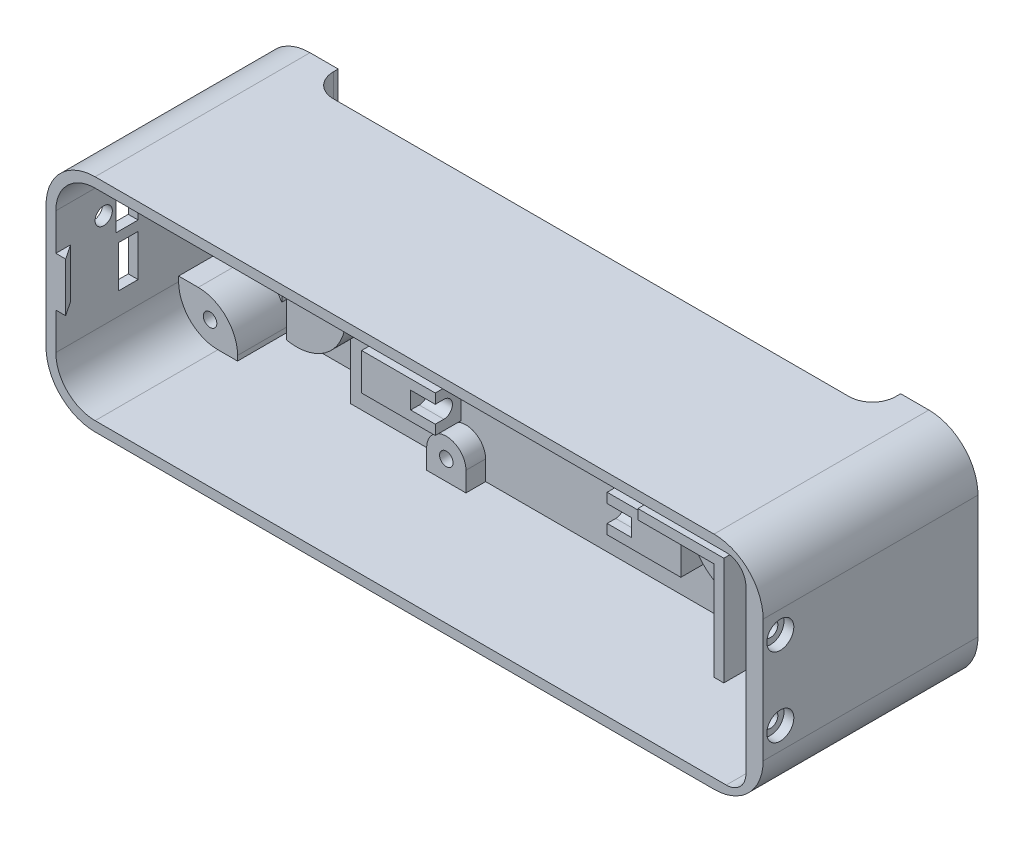
from build123d import *

# Parameters (mm, degrees)
BOSS_EXTRUDE1_DEPTH            = 7.75
CUT_EXTRUDE1_DEPTH             = 153.974058258
CUT_EXTRUDE1_DEPTH_BACK        = 153.974058258
SKETCH4_W                      = 80
SKETCH4_H                      = 45
BOSS_EXTRUDE2_DEPTH            = 6
SKETCH5_W                      = 70
SKETCH5_H                      = 35
CUT_EXTRUDE2_DEPTH             = 7
SKETCH7_R                      = 10
BOSS_EXTRUDE3_DEPTH            = 12
SKETCH6_R                      = 8.125
CUT_EXTRUDE4_DEPTH             = 7
CUT_EXTRUDE4_DEPTH_BACK        = 7
BOSS_EXTRUDE9_DEPTH            = 35
CUT_EXTRUDE5_REACH             = 155.229
SKETCH8_W                      = 25
SKETCH8_H                      = 11
CUT_EXTRUDE5_DIRECTION_2_DEPTH = 154.228791392
BOSS_EXTRUDE4_DEPTH            = 35
BOSS_EXTRUDE6_DEPTH            = 27.5
SKETCH15_W                     = 12
SKETCH15_H                     = 5
CUT_EXTRUDE8_DEPTH             = 157.735445924
CUT_EXTRUDE8_DEPTH_BACK        = 4.5
SKETCH18_W                     = 15
SKETCH18_H                     = 7.5
SKETCH18_W_2                   = 13.5
SKETCH18_W_3                   = 12.5
BOSS_EXTRUDE8_DEPTH            = 5.25
CUT_EXTRUDE16_DEPTH            = 40
CUT_EXTRUDE16_DEPTH_BACK       = 5
CUT_EXTRUDE14_DEPTH            = 5
CUT_EXTRUDE15_DEPTH            = 5
BOSS_EXTRUDE10_DEPTH           = 10
BOSS_EXTRUDE21_DEPTH           = 4
SKETCH24_R                     = 1.375
CUT_EXTRUDE13_DEPTH            = 6
CUT_EXTRUDE17_REACH            = 156.685
SKETCH30_R                     = 2.5
BOSS_EXTRUDE22_DEPTH           = 6
CUT_EXTRUDE18_DEPTH            = 3
SKETCH33_R                     = 1.75
CUT_EXTRUDE19_DEPTH            = 3
CUT_EXTRUDE20_REACH            = 144.705
SKETCH35_W                     = 3
SKETCH35_H                     = 8.75
SKETCH36_R                     = 2.75
CUT_EXTRUDE21_DEPTH            = 2
SKETCH37_R                     = 1.5
CUT_EXTRUDE22_DEPTH            = 1.5
BOSS_EXTRUDE23_DEPTH           = 5
BOSS_EXTRUDE23_DEPTH_BACK      = 5
CUT_EXTRUDE23_REACH            = 160.646
SKETCH39_W                     = 4.5
SKETCH39_H                     = 8.5
SKETCH39_W_2                   = 4
SKETCH39_R                     = 1.75
CUT_EXTRUDE24_DEPTH            = 12
CUT_EXTRUDE26_DEPTH            = 1
CHAMFER1_SIZE                  = 7
BOSS_EXTRUDE24_DEPTH           = 1


with BuildPart() as part:
    # Sketch2 → Boss-Extrude1 (new body)
    with BuildSketch(Plane.XY):
        with BuildLine():
            Line((-10, 0), (-136, 0))
            ThreePointArc((-136, 0), (-143.071067812, 2.928932188), (-146, 10))
            Line((-146, 10), (-146, 35))
            ThreePointArc((-146, 35), (-143.071067812, 42.071067812), (-136, 45))
            Line((-136, 45), (-10, 45))
            ThreePointArc((-10, 45), (-2.928932188, 42.071067812), (0, 35))
            Line((0, 35), (0, 10))
            ThreePointArc((0, 10), (-2.928932188, 2.928932188), (-10, 0))
        make_face()
    extrude(amount=BOSS_EXTRUDE1_DEPTH)

    # Sketch3 → Cut-Extrude1 (cut, two sides)
    with BuildSketch(Plane.XZ) as cut_extrude1_sk:
        with BuildLine():
            Line((-15.75, 0), (-130.25, 0))
            ThreePointArc((-130.25, 0), (-128.858757211, 3.358757211), (-125.5, 4.75))
            Line((-125.5, 4.75), (-20.5, 4.75))
            ThreePointArc((-20.5, 4.75), (-17.141242789, 3.358757211), (-15.75, 0))
        make_face()
    extrude(amount=CUT_EXTRUDE1_DEPTH, mode=Mode.SUBTRACT)
    extrude(cut_extrude1_sk.sketch, amount=-CUT_EXTRUDE1_DEPTH_BACK, mode=Mode.SUBTRACT)

    # Sketch4 → Boss-Extrude2 (add)
    with BuildSketch(Plane.XY.offset(7.75)):
        with Locations((-73, 22.5)):
            Rectangle(SKETCH4_W, SKETCH4_H)
    extrude(amount=BOSS_EXTRUDE2_DEPTH)

    # Sketch5 → Cut-Extrude2 (cut)
    with BuildSketch(Plane(origin=(0, 0, 4.75), x_dir=(-1, 0, 0), z_dir=(0, 0, -1))):
        with Locations((73, 22.5)):
            Rectangle(SKETCH5_W, SKETCH5_H)
    extrude(amount=-CUT_EXTRUDE2_DEPTH, mode=Mode.SUBTRACT)

    # Sketch7 → Boss-Extrude3 (add)
    with BuildSketch(Plane.XY.offset(7.75)):
        with Locations(Location((-28, 22.5, 0), (0, 0, 180))):
            Circle(SKETCH7_R)
        with Locations(Location((-118, 22.5, 0), (0, 0, 180))):
            Circle(SKETCH7_R)
    extrude(amount=BOSS_EXTRUDE3_DEPTH)

    # Sketch6 → Cut-Extrude4 (cut, two sides)
    with BuildSketch(Plane(origin=(0, 0, 4.75), x_dir=(-1, 0, 0), z_dir=(0, 0, -1))) as cut_extrude4_sk:
        with Locations(Location((118, 22.5, 0), (0, 0, 22.619864948))):
            Circle(SKETCH6_R)
        with Locations(Location((28, 22.5, 0), (0, 0, 157.380135052))):
            Circle(SKETCH6_R)
    extrude(amount=CUT_EXTRUDE4_DEPTH, mode=Mode.SUBTRACT)
    extrude(cut_extrude4_sk.sketch, amount=-CUT_EXTRUDE4_DEPTH_BACK, mode=Mode.SUBTRACT)

    # Sketch22 → Boss-Extrude9 (add)
    with BuildSketch(Plane.XZ.offset(-40)):
        Polygon((-73, 8.25), (-73, 11.75), (-92.849486369, 11.75), align=None)
        Polygon((-53.150513631, 11.75), (-73, 11.75), (-73, 8.25), align=None)
    extrude(amount=BOSS_EXTRUDE9_DEPTH)

    # Sketch8 → Cut-Extrude5 (cut, up to next)
    with BuildSketch(Plane(origin=(0, 0, 11.75), x_dir=(-1, 0, 0), z_dir=(0, 0, -1)), mode=Mode.PRIVATE) as cut_extrude5_sk1:
        with Locations((73, 22.5)):
            Rectangle(SKETCH8_W, SKETCH8_H)
    cut_extrude5_tool1 = extrude(cut_extrude5_sk1.sketch, amount=-CUT_EXTRUDE5_REACH, mode=Mode.PRIVATE) & part.part
    # Sketch8 → Cut-Extrude5 (cut, up to next)
    with BuildSketch(Plane(origin=(0, 0, 11.75), x_dir=(-1, 0, 0), z_dir=(0, 0, -1)), mode=Mode.PRIVATE) as cut_extrude5_sk2:
        Polygon((100.5, 31), (73, 31), (45.5, 31), (45.5, 35.5), (100.5, 35.5), align=None)
    cut_extrude5_tool2 = extrude(cut_extrude5_sk2.sketch, amount=-CUT_EXTRUDE5_REACH, mode=Mode.PRIVATE) & part.part
    add(cut_extrude5_tool1.solids().sort_by_distance((-73, 22.5, 11.75))[0], mode=Mode.SUBTRACT)
    add(cut_extrude5_tool2.solids().sort_by_distance((-73, 33.25, 11.75))[0], mode=Mode.SUBTRACT)

    # Sketch8 → Cut-Extrude5 direction 2 (cut)
    with BuildSketch(Plane(origin=(0, 0, 11.75), x_dir=(-1, 0, 0), z_dir=(0, 0, -1))):
        with Locations((73, 22.5)):
            Rectangle(SKETCH8_W, SKETCH8_H)
        Polygon((100.5, 31), (73, 31), (45.5, 31), (45.5, 35.5), (100.5, 35.5), align=None)
    extrude(amount=CUT_EXTRUDE5_DIRECTION_2_DEPTH, mode=Mode.SUBTRACT)

    # Sketch9 → Boss-Extrude4 (add)
    with BuildSketch(Plane.XY.offset(7.75)):
        with BuildLine():
            Line((-33, 0), (-113, 0))
            Line((-113, 0), (-136, 0))
            ThreePointArc((-136, 0), (-143.071067812, 2.928932188), (-146, 10))
            Line((-146, 10), (-146, 35))
            ThreePointArc((-146, 35), (-143.071067812, 42.071067812), (-136, 45))
            Line((-136, 45), (-113, 45))
            Line((-113, 45), (-33, 45))
            Line((-33, 45), (-10, 45))
            ThreePointArc((-10, 45), (-2.928932188, 42.071067812), (0, 35))
            Line((0, 35), (0, 10))
            ThreePointArc((0, 10), (-2.928932188, 2.928932188), (-10, 0))
            Line((-10, 0), (-33, 0))
        make_face()
        with BuildLine():
            Line((-33, 2), (-113, 2))
            Line((-113, 2), (-136, 2))
            ThreePointArc((-136, 2), (-141.656854249, 4.343145751), (-144, 10))
            Line((-144, 10), (-144, 35))
            ThreePointArc((-144, 35), (-141.656854249, 40.656854249), (-136, 43))
            Line((-136, 43), (-113, 43))
            Line((-113, 43), (-33, 43))
            Line((-33, 43), (-7.5, 43))
            ThreePointArc((-7.5, 43), (-4.671572875, 41.828427125), (-3.5, 39))
            Line((-3.5, 39), (-3.5, 6))
            ThreePointArc((-3.5, 6), (-4.671572875, 3.171572875), (-7.5, 2))
            Line((-7.5, 2), (-33, 2))
        make_face(mode=Mode.SUBTRACT)
    extrude(amount=BOSS_EXTRUDE4_DEPTH)

    # Sketch12 → Boss-Extrude6 (add)
    with BuildSketch(Plane.XY.offset(7.75)):
        with BuildLine():
            Line((-17.5, 43), (-17.5, 34.25))
            Line((-17.5, 34.25), (-33, 34.25))
            Line((-33, 34.25), (-33, 32.25))
            Line((-33, 32.25), (-17.5, 32.25))
            Line((-17.5, 32.25), (-17.5, 12.25))
            Line((-17.5, 12.25), (-15.5, 12.25))
            Line((-15.5, 12.25), (-15.5, 40))
            Line((-15.5, 40), (-12, 40))
            Line((-12, 40), (-12, 42))
            Line((-12, 42), (-7, 42))
            Line((-7, 42), (-7, 40))
            Line((-7, 40), (-3.627016654, 40))
            ThreePointArc((-3.627016654, 40), (-5.050510257, 42.16227766), (-7.5, 43))
            Line((-7.5, 43), (-17.5, 43))
        make_face()
    extrude(amount=BOSS_EXTRUDE6_DEPTH)

    # Sketch15 → Cut-Extrude8 (cut, two sides)
    with BuildSketch(Plane.XY.offset(7.75)) as cut_extrude8_sk:
        with Locations((-9.5, 20.5)):
            Rectangle(SKETCH15_W, SKETCH15_H)
    extrude(amount=CUT_EXTRUDE8_DEPTH, mode=Mode.SUBTRACT)
    extrude(cut_extrude8_sk.sketch, amount=-CUT_EXTRUDE8_DEPTH_BACK, mode=Mode.SUBTRACT)

    # Sketch18 → Boss-Extrude8 (add)
    with BuildSketch(Plane.XY.offset(13.75)):
        with Locations((-48, 14)):
            Rectangle(SKETCH18_W, SKETCH18_H)
        with Locations((-106.25, 39.25)):
            Rectangle(SKETCH18_W_2, SKETCH18_H)
        with Locations((-39.25, 39.25)):
            Rectangle(SKETCH18_W_3, SKETCH18_H)
        with Locations((-98, 14)):
            Rectangle(SKETCH18_W, SKETCH18_H)
    extrude(amount=BOSS_EXTRUDE8_DEPTH)

    # Sketch29 → Cut-Extrude16 (cut, two sides)
    with BuildSketch(Plane.ZY.offset(55.5)) as cut_extrude16_sk:
        with BuildLine():
            ThreePointArc((17.25, 15.75), (16.012563133, 15.237436867), (15.5, 14))
            ThreePointArc((15.5, 14), (16.012563133, 12.762563133), (17.25, 12.25))
            Line((17.25, 12.25), (19, 12.25))
            Line((19, 12.25), (19, 15.75))
            Line((19, 15.75), (17.25, 15.75))
        make_face()
    extrude(amount=CUT_EXTRUDE16_DEPTH, mode=Mode.SUBTRACT)
    extrude(cut_extrude16_sk.sketch, amount=-CUT_EXTRUDE16_DEPTH_BACK, mode=Mode.SUBTRACT)

    # Sketch27 → Cut-Extrude14 (cut)
    with BuildSketch(Plane.ZY.offset(45.5)):
        with BuildLine():
            ThreePointArc((17.25, 41), (16.012563133, 40.487436867), (15.5, 39.25))
            ThreePointArc((15.5, 39.25), (16.012563133, 38.012563133), (17.25, 37.5))
            Line((17.25, 37.5), (19, 37.5))
            Line((19, 37.5), (19, 41))
            Line((19, 41), (17.25, 41))
        make_face()
    extrude(amount=-CUT_EXTRUDE14_DEPTH, mode=Mode.SUBTRACT)

    # Sketch28 → Cut-Extrude15 (cut)
    with BuildSketch(Plane(origin=(-99.5, 0, 0), x_dir=(0, 0, -1), z_dir=(1, 0, 0))):
        with BuildLine():
            ThreePointArc((-17.25, 37.5), (-16.012563133, 38.012563133), (-15.5, 39.25))
            ThreePointArc((-15.5, 39.25), (-16.012563133, 40.487436867), (-17.25, 41))
            Line((-17.25, 41), (-19, 41))
            Line((-19, 41), (-19, 37.5))
            Line((-19, 37.5), (-17.25, 37.5))
        make_face()
    extrude(amount=-CUT_EXTRUDE15_DEPTH, mode=Mode.SUBTRACT)

    # Sketch23 → Boss-Extrude10 (add)
    with BuildSketch(Plane.XY.offset(7.75)):
        with BuildLine():
            ThreePointArc((-140, 34), (-134.343145751, 36.343145751), (-132, 42))
            Line((-132, 42), (-132, 43))
            Line((-132, 43), (-136, 43))
            ThreePointArc((-136, 43), (-141.656854249, 40.656854249), (-144, 35))
            Line((-144, 35), (-144, 34))
            Line((-144, 34), (-140, 34))
        make_face()
        with BuildLine():
            Line((-140, 11), (-144, 11))
            Line((-144, 11), (-144, 10))
            ThreePointArc((-144, 10), (-141.656854249, 4.343145751), (-136, 2))
            Line((-136, 2), (-132, 2))
            Line((-132, 2), (-132, 3))
            ThreePointArc((-132, 3), (-134.343145751, 8.656854249), (-140, 11))
        make_face()
    extrude(amount=BOSS_EXTRUDE10_DEPTH)

    # Sketch26 → Boss-Extrude21 (add)
    with BuildSketch(Plane.XY.offset(13.75)):
        with BuildLine():
            Line((-93.5, 2), (-85.5, 2))
            Line((-85.5, 2), (-85.5, 6))
            ThreePointArc((-85.5, 6), (-89.5, 10), (-93.5, 6))
            Line((-93.5, 6), (-93.5, 2))
        make_face()
    extrude(amount=BOSS_EXTRUDE21_DEPTH)

    # Sketch24 → Cut-Extrude13 (cut)
    with BuildSketch(Plane.XY.offset(17.75)):
        with Locations((-137.6, 6.5)):
            Circle(SKETCH24_R)
        with Locations((-137.6, 38.25)):
            Circle(SKETCH24_R)
        with Locations((-89.5, 6)):
            Circle(SKETCH24_R)
    extrude(amount=-CUT_EXTRUDE13_DEPTH, mode=Mode.SUBTRACT)

    # Cut-Extrude17: up to this face of the body (flat: up to its plane)
    cut_extrude17_end = Plane(part.part.faces().sort_by_distance((-75.365079921, 43, 27.97088825))[0])
    # Sketch30 → Cut-Extrude17 (cut, up to the picked face)
    with BuildSketch(Plane.XZ.offset(-28), mode=Mode.PRIVATE) as cut_extrude17_sk1:
        with Locations((-73, 13.75)):
            Circle(SKETCH30_R)
    cut_extrude17_tool1 = split(extrude(cut_extrude17_sk1.sketch, amount=-CUT_EXTRUDE17_REACH, mode=Mode.PRIVATE), bisect_by=cut_extrude17_end, keep=Keep.BOTH, mode=Mode.PRIVATE)
    add(cut_extrude17_tool1.solids().sort_by(Axis((-73, 28, 13.75), (0, 1, 0)))[0], mode=Mode.SUBTRACT)

    # Sketch31 → Boss-Extrude22 (add)
    with BuildSketch(Plane.XY.offset(13.75)):
        with BuildLine():
            Line((-104, 21.25), (-104, 32))
            Line((-104, 32), (-113, 32))
            Line((-113, 32), (-113, 31.160254038))
            ThreePointArc((-113, 31.160254038), (-109.043629233, 26.947855965), (-108.078432584, 21.25))
            Line((-108.078432584, 21.25), (-104, 21.25))
        make_face()
        with BuildLine():
            Line((-42, 21.25), (-37.921567416, 21.25))
            ThreePointArc((-37.921567416, 21.25), (-36.956370767, 26.947855965), (-33, 31.160254038))
            Line((-33, 31.160254038), (-33, 32))
            Line((-33, 32), (-42, 32))
            Line((-42, 32), (-42, 21.25))
        make_face()
    extrude(amount=BOSS_EXTRUDE22_DEPTH)

    # Sketch34 → Cut-Extrude18 (cut)
    with BuildSketch(Plane.XY.offset(13.75)):
        Polygon((-104, 23.25), (-104, 30), (-110.5, 30), (-112.448557159, 26.625), (-110.5, 23.25), align=None)
        Polygon((-35.5, 30), (-42, 30), (-42, 23.25), (-35.5, 23.25), (-33.551442841, 26.625), align=None)
    extrude(amount=CUT_EXTRUDE18_DEPTH, mode=Mode.SUBTRACT)

    # Sketch33 → Cut-Extrude19 (cut)
    with BuildSketch(Plane.XY.offset(19.75)):
        with Locations((-108.5, 26.625)):
            Circle(SKETCH33_R)
        with Locations((-37.5, 26.625)):
            Circle(SKETCH33_R)
    extrude(amount=-CUT_EXTRUDE19_DEPTH, mode=Mode.SUBTRACT)

    # Cut-Extrude20: up to this face of the body (flat: up to its plane)
    cut_extrude20_end = Plane(part.part.faces().sort_by_distance((-7, 41, 21.5))[0])
    # Sketch35 → Cut-Extrude20 (cut, up to the picked face)
    with BuildSketch(Plane.ZY.offset(17.5), mode=Mode.PRIVATE) as cut_extrude20_sk1:
        with Locations((33.75, 38.625)):
            Rectangle(SKETCH35_W, SKETCH35_H)
    cut_extrude20_tool1 = split(extrude(cut_extrude20_sk1.sketch, amount=-CUT_EXTRUDE20_REACH, mode=Mode.PRIVATE), bisect_by=cut_extrude20_end, keep=Keep.BOTH, mode=Mode.PRIVATE)
    add(cut_extrude20_tool1.solids().sort_by(Axis((-17.5, 38.625, 33.75), (1, 0, 0)))[0], mode=Mode.SUBTRACT)

    # Sketch36 → Cut-Extrude21 (cut)
    with BuildSketch(Plane(origin=(0, 0, 0), x_dir=(0, 0, -1), z_dir=(1, 0, 0))):
        with Locations(Location((-39.25, 30.5, 0), (0, 0, 90))):
            Circle(SKETCH36_R)
        with Locations(Location((-39.25, 14.5, 0), (0, 0, 90))):
            Circle(SKETCH36_R)
    extrude(amount=-CUT_EXTRUDE21_DEPTH, mode=Mode.SUBTRACT)

    # Sketch37 → Cut-Extrude22 (cut)
    with BuildSketch(Plane(origin=(-2, 0, 0), x_dir=(0, 0, -1), z_dir=(1, 0, 0))):
        with Locations(Location((-39.25, 14.5, 0), (0, 0, 90))):
            Circle(SKETCH37_R)
        with Locations(Location((-39.25, 30.5, 0), (0, 0, 90))):
            Circle(SKETCH37_R)
    extrude(amount=-CUT_EXTRUDE22_DEPTH, mode=Mode.SUBTRACT)

    # Sketch38 → Boss-Extrude23 (add, two sides)
    with BuildSketch(Plane(origin=(0, 22.5, 0), x_dir=(1, 0, 0), z_dir=(0, 1, 0))) as boss_extrude23_sk:
        Polygon((-144, -39.75), (-144, -42.75), (-142, -42.75), align=None)
    extrude(amount=BOSS_EXTRUDE23_DEPTH)
    extrude(boss_extrude23_sk.sketch, amount=-BOSS_EXTRUDE23_DEPTH_BACK)

    # Sketch39 → Cut-Extrude23 (cut, up to next)
    with BuildSketch(Plane.ZY.offset(146), mode=Mode.PRIVATE) as cut_extrude23_sk1:
        with Locations((28.25, 29.25)):
            Rectangle(SKETCH39_W, SKETCH39_H)
    cut_extrude23_tool1 = extrude(cut_extrude23_sk1.sketch, amount=-CUT_EXTRUDE23_REACH, mode=Mode.PRIVATE) & part.part
    # Sketch39 → Cut-Extrude23 (cut, up to next)
    with BuildSketch(Plane.ZY.offset(146), mode=Mode.PRIVATE) as cut_extrude23_sk2:
        with Locations((28, 18.75)):
            Rectangle(SKETCH39_W_2, SKETCH39_H)
    cut_extrude23_tool2 = extrude(cut_extrude23_sk2.sketch, amount=-CUT_EXTRUDE23_REACH, mode=Mode.PRIVATE) & part.part
    # Sketch39 → Cut-Extrude23 (cut, up to next)
    with BuildSketch(Plane.ZY.offset(146), mode=Mode.PRIVATE) as cut_extrude23_sk3:
        with Locations((33, 29.25)):
            Circle(SKETCH39_R)
    cut_extrude23_tool3 = extrude(cut_extrude23_sk3.sketch, amount=-CUT_EXTRUDE23_REACH, mode=Mode.PRIVATE) & part.part
    add(cut_extrude23_tool1.solids().sort_by_distance((-146, 29.25, 28.25))[0], mode=Mode.SUBTRACT)
    add(cut_extrude23_tool2.solids().sort_by_distance((-146, 18.75, 28))[0], mode=Mode.SUBTRACT)
    add(cut_extrude23_tool3.solids().sort_by_distance((-146, 29.25, 33))[0], mode=Mode.SUBTRACT)

    # Sketch40 → Cut-Extrude24 (cut)
    with BuildSketch(Plane.XY.offset(19.75)):
        with BuildLine():
            ThreePointArc((-128, 22.5), (-127.746794345, 20.263932023), (-127, 18.141101056))
            Line((-127, 18.141101056), (-127, 26.858898944))
            ThreePointArc((-127, 26.858898944), (-127.746794345, 24.736067977), (-128, 22.5))
        make_face()
    extrude(amount=-CUT_EXTRUDE24_DEPTH, mode=Mode.SUBTRACT)

    # Sketch42 → Cut-Extrude26 (cut)
    with BuildSketch(Plane.XY.offset(7.75)):
        with BuildLine():
            Line((-133, 34.624822999), (-133, 6.872983346))
            ThreePointArc((-133, 6.872983346), (-132.254033308, 5), (-132, 3))
            Line((-132, 3), (-132, 2))
            Line((-132, 2), (-127, 2))
            Line((-127, 2), (-127, 18.141101056))
            Line((-127, 18.141101056), (-127, 26.858898944))
            Line((-127, 26.858898944), (-127, 34.624822999))
            Line((-127, 34.624822999), (-133, 34.624822999))
        make_face()
    extrude(amount=-CUT_EXTRUDE26_DEPTH, mode=Mode.SUBTRACT)

    # Chamfer1
    chamfer1_edges = [part.edges().sort_by_distance(p)[0] for p in [
        (-127, 22.5, 19.75),
    ]]
    chamfer(chamfer1_edges, length=CHAMFER1_SIZE)

    # Sketch43 → Boss-Extrude24 (add)
    with BuildSketch(Plane(origin=(0, 0, 0), x_dir=(-1, 0, 0), z_dir=(0, 0, -1))):
        with BuildLine():
            Line((10, 0), (15.75, 0))
            Line((15.75, 0), (15.75, 45))
            Line((15.75, 45), (10, 45))
            ThreePointArc((10, 45), (2.928932188, 42.071067812), (0, 35))
            Line((0, 35), (0, 10))
            ThreePointArc((0, 10), (2.928932188, 2.928932188), (10, 0))
        make_face()
        with BuildLine():
            Line((136, 45), (130.25, 45))
            Line((130.25, 45), (130.25, 0))
            Line((130.25, 0), (136, 0))
            ThreePointArc((136, 0), (143.071067812, 2.928932188), (146, 10))
            Line((146, 10), (146, 35))
            ThreePointArc((146, 35), (143.071067812, 42.071067812), (136, 45))
        make_face()
    extrude(amount=BOSS_EXTRUDE24_DEPTH)


solid = part.part
